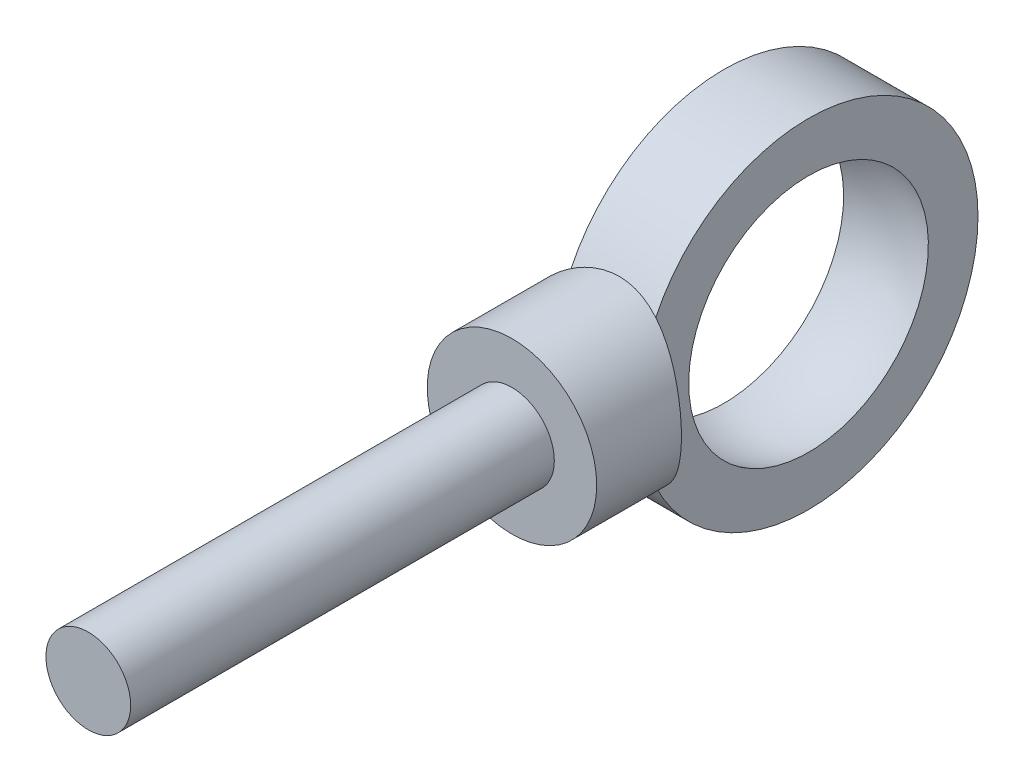
from build123d import *

# Parameters (mm, degrees)
BOSS_EXTRUDE1_REACH      = 56.083
BOSS_EXTRUDE1_END_RADIUS = 20
SKETCH2_R                = 10
SKETCH3_R                = 5
BOSS_EXTRUDE2_DEPTH      = 50


with BuildPart() as part:
    # Sketch1 → Revolve1 (revolve)
    with BuildSketch(Plane.XY):
        with BuildLine():
            Line((-5, 20), (5, 20))
            Line((5, 20), (5, 14.142135624))
            ThreePointArc((5, 14.142135624), (0, 15), (-5, 14.142135624))
            Line((-5, 14.142135624), (-5, 20))
        make_face()
    revolve(axis=Axis((25.861561119, 0, 0), (-1, 0, 0)))

    # Boss-Extrude1: up to this cylinder (the profile starts outside it)
    boss_extrude1_end = Plane(origin=(0, 0, 0), z_dir=(1, 0, 0)) * Cylinder(BOSS_EXTRUDE1_END_RADIUS, 153.166, mode=Mode.PRIVATE)
    # Sketch2 → Boss-Extrude1 (add, up to the surface)
    with BuildSketch(Plane.XY.offset(30), mode=Mode.PRIVATE) as boss_extrude1_sk1:
        Circle(SKETCH2_R)
    boss_extrude1_tool1 = extrude(boss_extrude1_sk1.sketch, amount=-BOSS_EXTRUDE1_REACH, mode=Mode.PRIVATE) - boss_extrude1_end
    add(boss_extrude1_tool1.solids().sort_by_distance((0, 0, 30))[0])

    # Sketch3 → Boss-Extrude2 (add)
    with BuildSketch(Plane.XY.offset(30)):
        Circle(SKETCH3_R)
    extrude(amount=BOSS_EXTRUDE2_DEPTH)


solid = part.part
